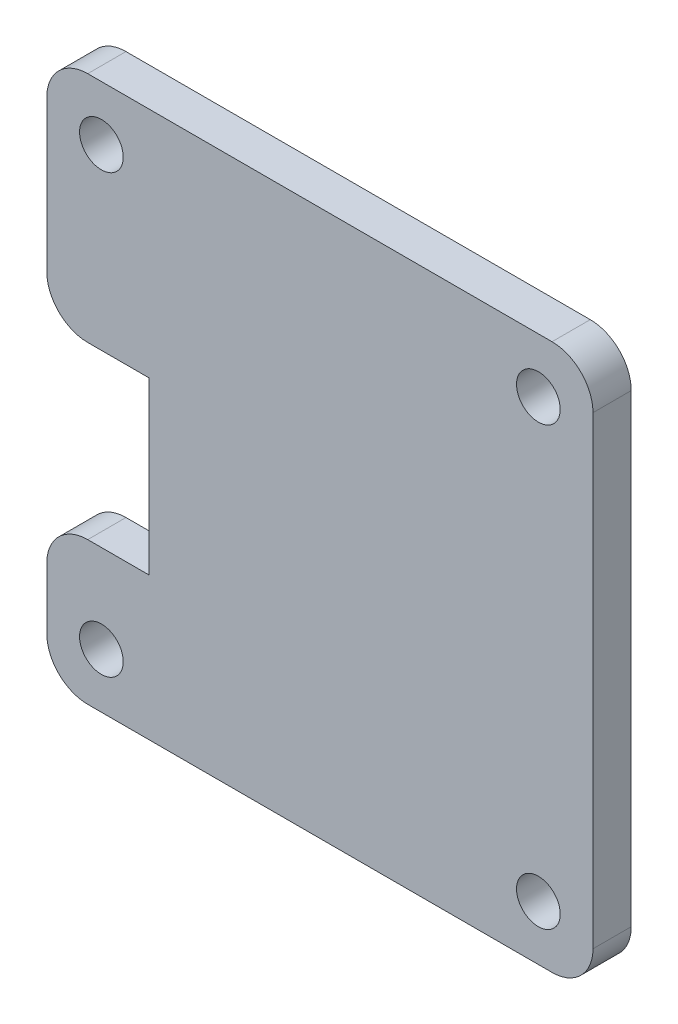
from build123d import *

# Parameters (mm, degrees)
SKETCH1_R           = 1.6
BOSS_EXTRUDE1_DEPTH = 2.8
FILLET1_R           = 3


with BuildPart() as part:
    # Sketch1 → Boss-Extrude1 (new body)
    with BuildSketch(Plane.XY):
        Polygon((-20, 20), (20, 20), (20, -20), (-20, -20), (-20, -9.55), (-12.5, -9.55), (-12.5, 2.95), (-20, 2.95), align=None)
        with Locations((-16, 16)):
            Circle(SKETCH1_R, mode=Mode.SUBTRACT)
        with Locations((16, 16)):
            Circle(SKETCH1_R, mode=Mode.SUBTRACT)
        with Locations((16, -16)):
            Circle(SKETCH1_R, mode=Mode.SUBTRACT)
        with Locations((-16, -16)):
            Circle(SKETCH1_R, mode=Mode.SUBTRACT)
    extrude(amount=BOSS_EXTRUDE1_DEPTH)

    # Fillet1
    fillet1_edges = [part.edges().sort_by_distance(p)[0] for p in [
        (20, -20, 1.4),
        (-20, -20, 1.4),
        (-20, -9.55, 1.4),
        (-20, 2.95, 1.4),
        (-20, 20, 1.4),
        (20, 20, 1.4),
    ]]
    fillet(fillet1_edges, radius=FILLET1_R)


solid = part.part
